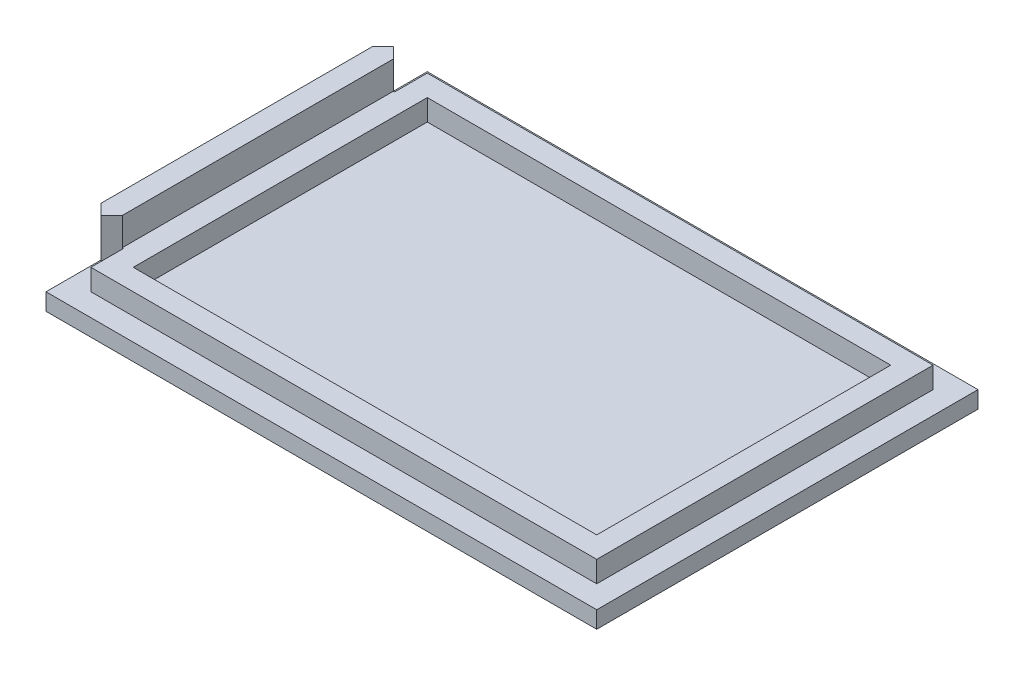
from build123d import *

# Parameters (mm, degrees)
SKETCH_1_W          = 65
SKETCH_1_H          = 45
EXTRUDE_1_DEPTH     = 2
SKETCH_2_W          = 59.7
SKETCH_2_H          = 39.7
EXTRUDE_2_DEPTH     = 2.5
EXTRUDE_3_DEPTH     = 5.8
SKETCH_4_W          = 0.15
SKETCH_4_H          = 32
CUT_EXTRUDE_1_DEPTH = 3.3
SKETCH_5_W          = 54.7
SKETCH_5_H          = 34.7
CUT_EXTRUDE_2_DEPTH = 2.5


with BuildPart() as part:
    # 草图1 → 凸台-拉伸1 (new body)
    with BuildSketch(Plane(origin=(0, 0, 0), x_dir=(1, 0, 0), z_dir=(0, 1, 0))):
        Rectangle(SKETCH_1_W, SKETCH_1_H)
    extrude(amount=EXTRUDE_1_DEPTH)

    # 草图2 → 凸台-拉伸2 (add)
    with BuildSketch(Plane(origin=(0, 2, 0), x_dir=(1, 0, 0), z_dir=(0, 1, 0))):
        Rectangle(SKETCH_2_W, SKETCH_2_H)
    extrude(amount=EXTRUDE_2_DEPTH)

    # 草图3 → 凸台-拉伸3 (add)
    with BuildSketch(Plane(origin=(0, 2, 0), x_dir=(1, 0, 0), z_dir=(0, 1, 0))):
        Polygon((-30, -16), (-29.85, -16), (-29.85, 16), (-30, 16), (-31.25, 17.25), (-32.5, 16), (-32.5, -16), (-31.25, -17.25), align=None)
    extrude(amount=EXTRUDE_3_DEPTH)

    # 草图4 → 切除-拉伸1 (cut)
    with BuildSketch(Plane(origin=(0, 7.8, 0), x_dir=(1, 0, 0), z_dir=(0, 1, 0))):
        with Locations((-29.925, 0)):
            Rectangle(SKETCH_4_W, SKETCH_4_H)
    extrude(amount=-CUT_EXTRUDE_1_DEPTH, mode=Mode.SUBTRACT)

    # 草图5 → 切除-拉伸2 (cut)
    with BuildSketch(Plane(origin=(0, 4.5, 0), x_dir=(1, 0, 0), z_dir=(0, 1, 0))):
        Rectangle(SKETCH_5_W, SKETCH_5_H)
    extrude(amount=-CUT_EXTRUDE_2_DEPTH, mode=Mode.SUBTRACT)


solid = part.part
